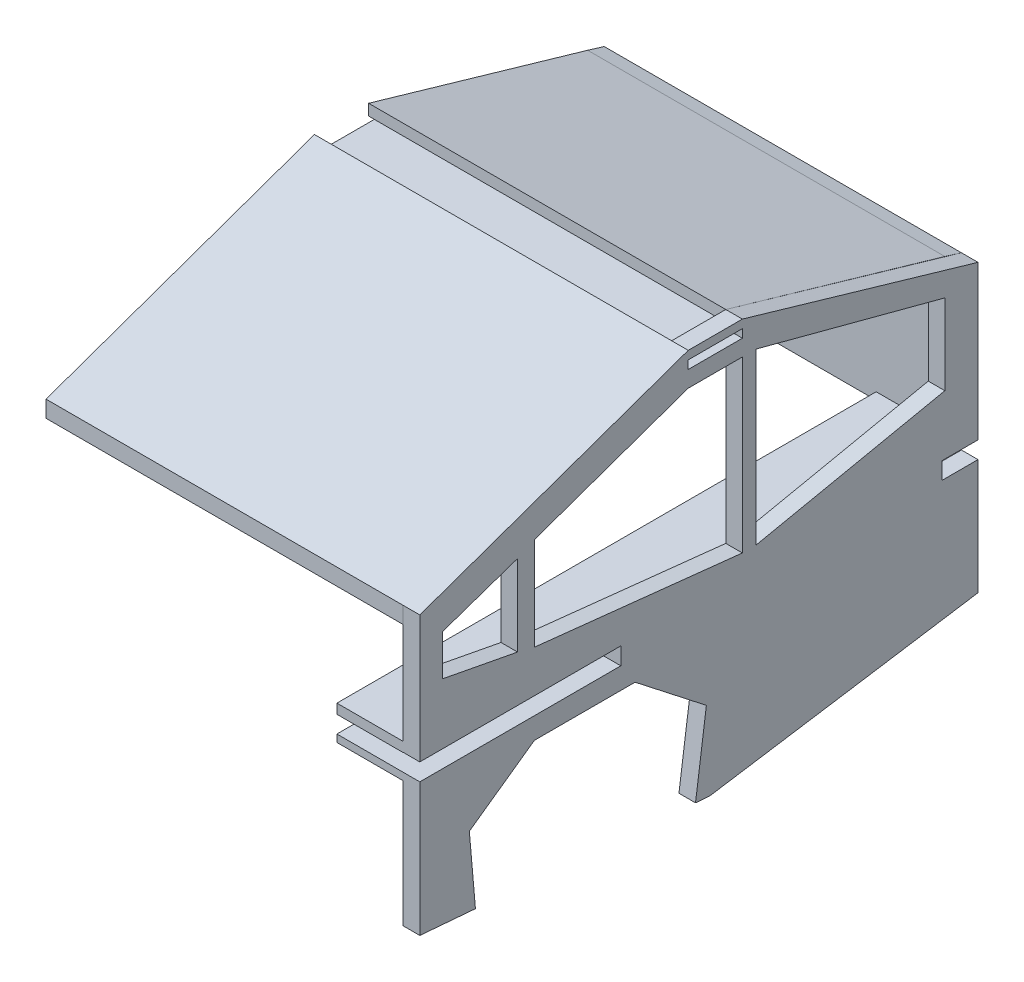
from build123d import *

# Parameters (mm, degrees)
SKETCH1_W           = 20.735936364
SKETCH1_H           = 3.175
BOSS_EXTRUDE1_DEPTH = 6.35
SKETCH2_W           = 82.651107169
SKETCH2_H           = 6.52720724
SKETCH2_W_2         = 76.969823319
SKETCH2_H_2         = 6.604
CUT_EXTRUDE1_DEPTH  = 7.35
SKETCH6_W           = 206.502
SKETCH6_H           = 3.711703494
SKETCH6_H_2         = 2.816288331
BOSS_EXTRUDE3_DEPTH = 25.4
BOSS_EXTRUDE5_DEPTH = 136.779


with BuildPart() as part:
    # Sketch1 → Boss-Extrude1 (new body)
    with BuildSketch(Plane(origin=(0, 0, 0), x_dir=(0, 0, -1), z_dir=(1, 0, 0))):
        Polygon((-123.525645009, 81.218983384), (-123.525645009, -25.082949612), (-102.22101814, -26.860004783), (-104.557017494, 0), (-79.646789796, 17.686261666), (-41.094549164, 17.686261666), (-13.779824281, -3.641289166), (-17.947471695, -33.889404663), (-12.561862574, -34.338627482), (90.228248196, -18.303088648), (90.228248196, 91.281577209), (0, 117.577378193), (-20.735936364, 117.577378193), align=None)
        Polygon((5.201841666, 40.001048477), (77.528248196, 55.056292197), (77.528248196, 85.830387495), (5.201841666, 105.015188817), align=None, mode=Mode.SUBTRACT)
        Polygon((-79.646789796, 84.224142025), (-79.646789796, 48.574048336), (0, 40.007327233), (0, 105.015188817), (-20.735936364, 105.015188817), align=None, mode=Mode.SUBTRACT)
        Polygon((-86.090479579, 81.218983384), (-86.090479579, 50.197772081), (-114.759972161, 55.666680192), (-114.759972161, 71.350976637), align=None, mode=Mode.SUBTRACT)
        with Locations((-10.367968182, 112.814878193)):
            Rectangle(SKETCH1_W, SKETCH1_H, mode=Mode.SUBTRACT)
    extrude(amount=BOSS_EXTRUDE1_DEPTH)

    # Sketch2 → Cut-Extrude1 (cut, through all)
    with BuildSketch(Plane(origin=(6.35, 0, 0), x_dir=(0, 0, -1), z_dir=(1, 0, 0))):
        with Locations((117.850801407, 29.125465717)):
            Rectangle(SKETCH2_W, SKETCH2_H)
        with Locations((-85.04073335, 29.163862097)):
            Rectangle(SKETCH2_W_2, SKETCH2_H_2)
    extrude(amount=-CUT_EXTRUDE1_DEPTH, mode=Mode.SUBTRACT)

    # Sketch6 → Boss-Extrude3 (add)
    with BuildSketch(Plane.ZY):
        with Locations((20.274645009, 34.244921084)):
            Rectangle(SKETCH6_W, SKETCH6_H)
        with Locations((20.274645009, 24.453717932)):
            Rectangle(SKETCH6_W, SKETCH6_H_2)
    extrude(amount=BOSS_EXTRUDE3_DEPTH)

    # Sketch8 → Boss-Extrude5 (add)
    with BuildSketch(Plane.ZY):
        Polygon((0, 117.577378193), (-83.878248196, 93.218298083), (-90.228248196, 91.281577209), (-90.228248196, 32.389069337), (-83.878248196, 32.389069337), (-83.878248196, 86.868298083), (-9.525197863, 108.461165703), (29.097772116, 108.270149457), (123.542635704, 74.868983384), (123.525645009, 81.218983384), (20.735936364, 117.577378193), (20.752927059, 113.344232588), (26.228286967, 113.344232588), (26.228286967, 111.139694939), (20.752927059, 111.139694939), (0.016990695, 111.139694939), (-7.377605414, 111.139694939), (-7.377605414, 113.344232588), (0.011172356, 113.344232588), align=None)
    extrude(amount=BOSS_EXTRUDE5_DEPTH)


solid = part.part
